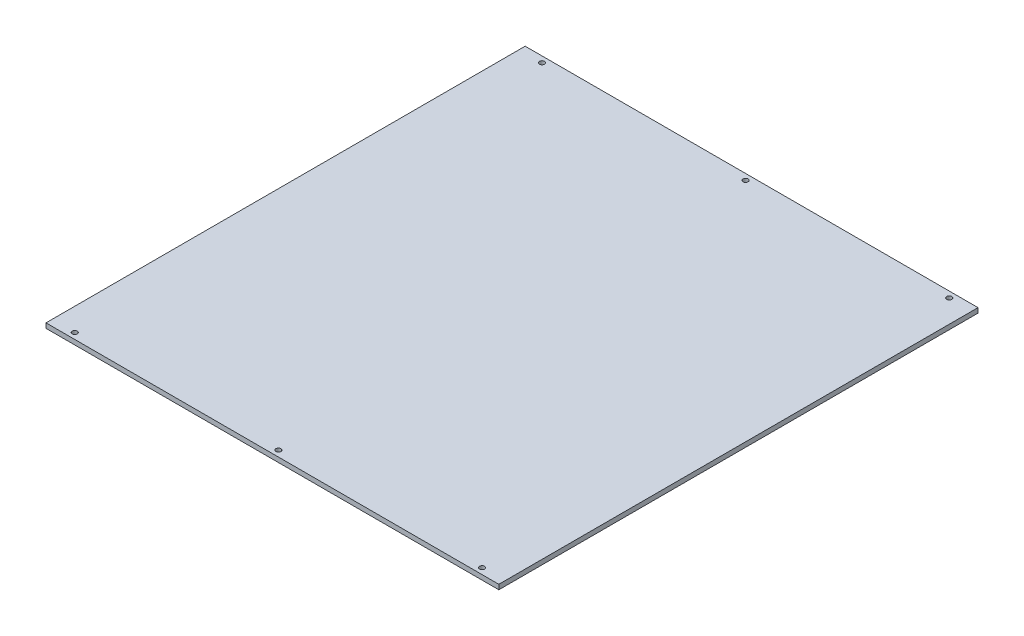
from build123d import *

# Parameters (mm, degrees)
SKETCH_1_W                  = 189
SKETCH_1_H                  = 200
EXTRUDE_1_DEPTH             = 2
SKETCH_2_R                  = 1.05
CUT_EXTRUDE_1_DEPTH         = 10
PATTERN_LINEAR_1_COUNT      = 2
PATTERN_LINEAR_1_PITCH      = 195
PATTERN_LINEAR_1_COUNT_DIR2 = 3
PATTERN_LINEAR_1_PITCH_DIR2 = 85


with BuildPart() as part:
    # 草图1 → 凸台-拉伸1 (new body)
    with BuildSketch(Plane(origin=(0, 0, 0), x_dir=(1, 0, 0), z_dir=(0, 1, 0))):
        with Locations((-419.32983733, 89.440084541)):
            Rectangle(SKETCH_1_W, SKETCH_1_H)
    extrude(amount=EXTRUDE_1_DEPTH)

    # 草图2 → 切除-拉伸1 (cut)
    with BuildSketch(Plane(origin=(0, 2, 0), x_dir=(1, 0, 0), z_dir=(0, 1, 0))):
        with Locations((-504.32983733, -8.059915459)):
            Circle(SKETCH_2_R)
    cut_extrude_1 = extrude(amount=-CUT_EXTRUDE_1_DEPTH, mode=Mode.SUBTRACT)

    # 阵列(线性)1: Cut-Extrude 1 2 × 3
    with Locations(*[(j * PATTERN_LINEAR_1_PITCH_DIR2, 0, -i * PATTERN_LINEAR_1_PITCH) for i in range(PATTERN_LINEAR_1_COUNT) for j in range(PATTERN_LINEAR_1_COUNT_DIR2) if (i, j) != (0, 0)]):
        add(cut_extrude_1, mode=Mode.SUBTRACT)


solid = part.part
